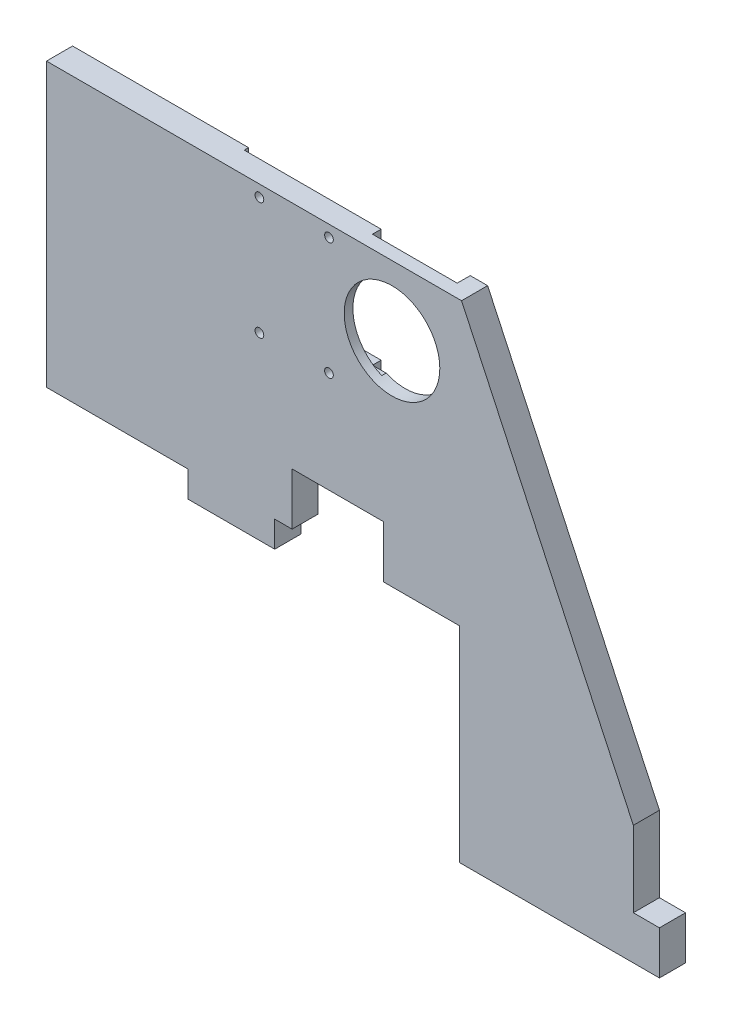
from build123d import *

# Parameters (mm, degrees)
ESQUISSE1_W             = 135
ESQUISSE1_H             = 112.17
BOSS_EXTRU_1_DEPTH      = 6
ENL_V_MAT_EXTRU_1_DEPTH = 6
ESQUISSE3_W             = 6
ESQUISSE3_H             = 10
ESQUISSE3_W_2           = 20
ESQUISSE3_H_2           = 6
BOSS_EXTRU_2_DEPTH      = 6
ESQUISSE4_W             = 51
ESQUISSE4_H             = 32
ENL_V_MAT_EXTRU_5_DEPTH = 3
ESQUISSE7_R             = 11
ENL_V_MAT_EXTRU_6_DEPTH = 4
ESQUISSE8_W             = 30
ESQUISSE8_H             = 20.2
ENL_V_MAT_EXTRU_7_DEPTH = 1
ESQUISSE9_W             = 25
ESQUISSE9_H             = 5.9
BOSS_EXTRU_4_DEPTH      = 2
ESQUISSE10_W            = 25
ESQUISSE10_H            = 5.9
BOSS_EXTRU_5_DEPTH      = 2
ESQUISSE11_W            = 6.5
ESQUISSE11_H            = 32
BOSS_EXTRU_6_DEPTH      = 2
ESQUISSE12_R            = 1
ENL_V_MAT_EXTRU_8_DEPTH = 6
ESQUISSE13_W            = 21
ESQUISSE13_H            = 12
ENL_V_MAT_EXTRU_9_DEPTH = 6


with BuildPart() as part:
    # Esquisse1 → Boss.-Extru.1 (new body)
    with BuildSketch(Plane.XY):
        Rectangle(ESQUISSE1_W, ESQUISSE1_H)
    extrude(amount=BOSS_EXTRU_1_DEPTH)

    # Esquisse2 → Enlèv. mat.-Extru.1 (cut)
    with BuildSketch(Plane.XY.offset(6)):
        Polygon((27.5, -56.085), (-67.5, -56.085), (-67.5, -8.915), (-38.5, -8.915), (27.5, -8.915), align=None)
        Polygon((67.5, -28.665), (27.980425971, 56.085), (67.5, 56.085), align=None)
    extrude(amount=-ENL_V_MAT_EXTRU_1_DEPTH, mode=Mode.SUBTRACT)

    # Esquisse3 → Boss.-Extru.2 (add)
    with BuildSketch(Plane.XY.offset(6)):
        with Locations((70.5, -51.085)):
            Rectangle(ESQUISSE3_W, ESQUISSE3_H)
        with Locations((-25, -11.915)):
            Rectangle(ESQUISSE3_W_2, ESQUISSE3_H_2)
    extrude(amount=-BOSS_EXTRU_2_DEPTH)

    # Esquisse4 → Enlèv. mat.-Extru.5 (cut)
    with BuildSketch(Plane(origin=(0, 0, 0), x_dir=(-1, 0, 0), z_dir=(0, 0, -1))):
        with Locations((1.519574029, 40.085)):
            Rectangle(ESQUISSE4_W, ESQUISSE4_H)
    extrude(amount=-ENL_V_MAT_EXTRU_5_DEPTH, mode=Mode.SUBTRACT)

    # Esquisse7 → Enlèv. mat.-Extru.6 (cut, through all)
    with BuildSketch(Plane(origin=(0, 0, 3), x_dir=(-1, 0, 0), z_dir=(0, 0, -1))):
        with Locations((-11.980425971, 40.085)):
            Circle(ESQUISSE7_R)
    extrude(amount=-ENL_V_MAT_EXTRU_6_DEPTH, mode=Mode.SUBTRACT)

    # Esquisse8 → Enlèv. mat.-Extru.7 (cut)
    with BuildSketch(Plane(origin=(0, 0, 3), x_dir=(-1, 0, 0), z_dir=(0, 0, -1))):
        with Locations((5.519574029, 40.085)):
            Rectangle(ESQUISSE8_W, ESQUISSE8_H)
    extrude(amount=-ENL_V_MAT_EXTRU_7_DEPTH, mode=Mode.SUBTRACT)

    # Esquisse9 → Boss.-Extru.4 (add)
    with BuildSketch(Plane(origin=(0, 0, 3), x_dir=(-1, 0, 0), z_dir=(0, 0, -1))):
        with Locations((8.019574029, 53.135)):
            Rectangle(ESQUISSE9_W, ESQUISSE9_H)
    extrude(amount=BOSS_EXTRU_4_DEPTH)

    # Esquisse10 → Boss.-Extru.5 (add)
    with BuildSketch(Plane(origin=(0, 0, 3), x_dir=(-1, 0, 0), z_dir=(0, 0, -1))):
        with Locations((8.019574029, 27.035)):
            Rectangle(ESQUISSE10_W, ESQUISSE10_H)
    extrude(amount=BOSS_EXTRU_5_DEPTH)

    # Esquisse11 → Boss.-Extru.6 (add)
    with BuildSketch(Plane(origin=(0, 0, 3), x_dir=(-1, 0, 0), z_dir=(0, 0, -1))):
        with Locations((23.769574029, 40.085)):
            Rectangle(ESQUISSE11_W, ESQUISSE11_H)
    extrude(amount=BOSS_EXTRU_6_DEPTH)

    # Esquisse12 → Enlèv. mat.-Extru.8 (cut, through all)
    with BuildSketch(Plane(origin=(0, 0, 1), x_dir=(-1, 0, 0), z_dir=(0, 0, -1))):
        with Locations((2.519574029, 53.435)):
            Circle(ESQUISSE12_R)
        with Locations((18.519574029, 53.435)):
            Circle(ESQUISSE12_R)
        with Locations((2.519574029, 26.435)):
            Circle(ESQUISSE12_R)
        with Locations((18.519574029, 26.435)):
            Circle(ESQUISSE12_R)
    extrude(amount=-ENL_V_MAT_EXTRU_8_DEPTH, mode=Mode.SUBTRACT)

    # Esquisse13 → Enlèv. mat.-Extru.9 (cut)
    with BuildSketch(Plane.XY.offset(6)):
        with Locations((-0.5, -2.915)):
            Rectangle(ESQUISSE13_W, ESQUISSE13_H)
    extrude(amount=-ENL_V_MAT_EXTRU_9_DEPTH, mode=Mode.SUBTRACT)


solid = part.part
